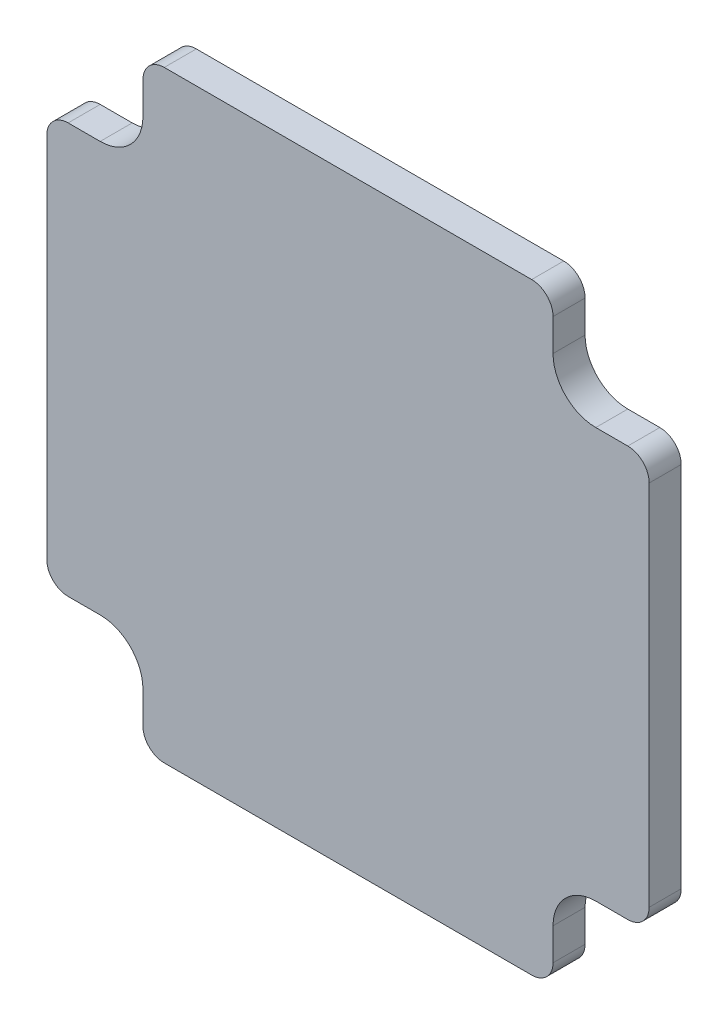
from build123d import *

# Parameters (mm, degrees)
EXTRUDE_1_DEPTH = 3


with BuildPart() as part:
    # 草图1 → 凸台-拉伸1 (new body)
    with BuildSketch(Plane.XY):
        with BuildLine():
            Line((28.2, -17.2), (28.2, 17.2))
            ThreePointArc((28.2, 17.2), (27.614213562, 18.614213562), (26.2, 19.2))
            Line((26.2, 19.2), (23.2, 19.2))
            ThreePointArc((23.2, 19.2), (20.371572875, 20.371572875), (19.2, 23.2))
            Line((19.2, 23.2), (19.2, 26.2))
            ThreePointArc((19.2, 26.2), (18.614213562, 27.614213562), (17.2, 28.2))
            Line((17.2, 28.2), (-17.2, 28.2))
            ThreePointArc((-17.2, 28.2), (-18.614213562, 27.614213562), (-19.2, 26.2))
            Line((-19.2, 26.2), (-19.2, 23.2))
            ThreePointArc((-19.2, 23.2), (-20.371572875, 20.371572875), (-23.2, 19.2))
            Line((-23.2, 19.2), (-26.2, 19.2))
            ThreePointArc((-26.2, 19.2), (-27.614213562, 18.614213562), (-28.2, 17.2))
            Line((-28.2, 17.2), (-28.2, -17.2))
            ThreePointArc((-28.2, -17.2), (-27.614213562, -18.614213562), (-26.2, -19.2))
            Line((-26.2, -19.2), (-23.2, -19.2))
            ThreePointArc((-23.2, -19.2), (-20.371572875, -20.371572875), (-19.2, -23.2))
            Line((-19.2, -23.2), (-19.2, -26.2))
            ThreePointArc((-19.2, -26.2), (-18.614213562, -27.614213562), (-17.2, -28.2))
            Line((-17.2, -28.2), (17.2, -28.2))
            ThreePointArc((17.2, -28.2), (18.614213562, -27.614213562), (19.2, -26.2))
            Line((19.2, -26.2), (19.2, -23.2))
            ThreePointArc((19.2, -23.2), (20.371572875, -20.371572875), (23.2, -19.2))
            Line((23.2, -19.2), (26.2, -19.2))
            ThreePointArc((26.2, -19.2), (27.614213562, -18.614213562), (28.2, -17.2))
        make_face()
    extrude(amount=EXTRUDE_1_DEPTH)


solid = part.part
